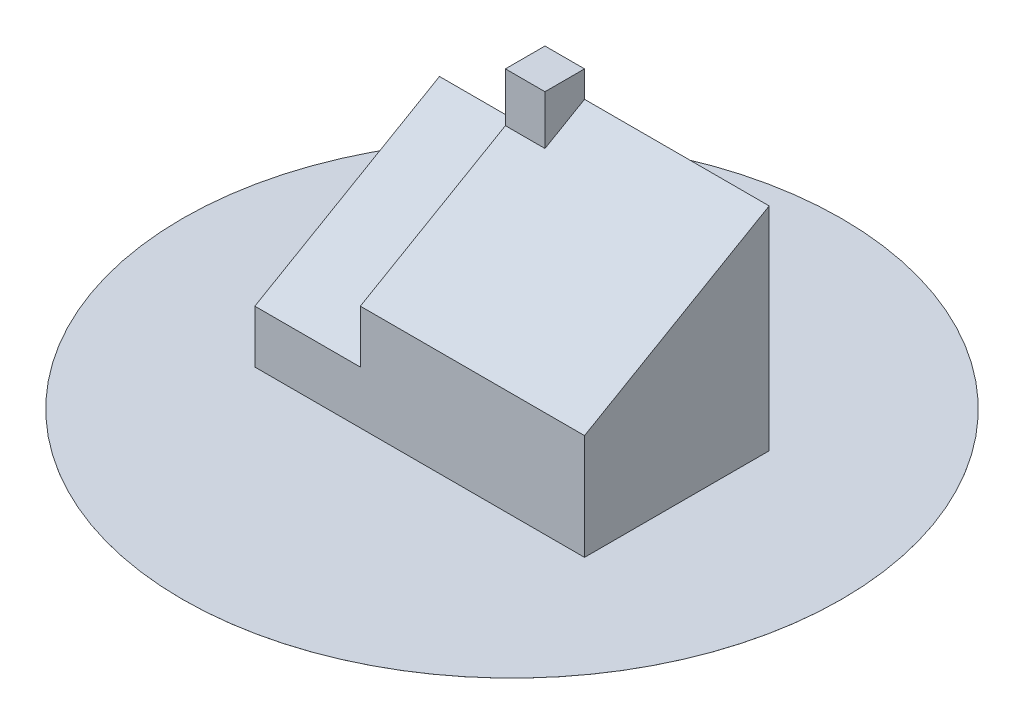
from build123d import *

# Parameters (mm, degrees)
SKETCH1_W           = 125
SKETCH1_H           = 70
EXTRUDE1_DEPTH      = 20
EXTRUDE2_DEPTH      = 40
EXTRUDE3_DEPTH      = 85
SKETCH5_W           = 15
SKETCH5_H           = 15
EXTRUDE5_DEPTH      = 10
EXTRUDE5_DEPTH_BACK = 20
SKETCH6_R           = 125
EXTRUDE6_DEPTH      = 0.01


with BuildPart() as part:
    # Sketch1 → Extrude1 (new body)
    with BuildSketch(Plane(origin=(0, 0, 0), x_dir=(1, 0, 0), z_dir=(0, 1, 0))):
        with Locations((62.5, -35)):
            Rectangle(SKETCH1_W, SKETCH1_H)
    extrude(amount=EXTRUDE1_DEPTH)

    # Sketch2 → Extrude2 (add)
    with BuildSketch(Plane.ZY):
        Polygon((0, 20), (70, 20), (0, 60.414518843), align=None)
    extrude(amount=-EXTRUDE2_DEPTH)

    # Sketch3 → Extrude3 (add)
    with BuildSketch(Plane(origin=(125, 0, 0), x_dir=(0, 0, -1), z_dir=(1, 0, 0))):
        Polygon((-70, 20), (-70, 40), (0, 80.414518843), (0, 20), align=None)
    extrude(amount=-EXTRUDE3_DEPTH)

    # Sketch5 → Extrude5 (add, two sides)
    with BuildSketch(Plane(origin=(0, 80.414518843, 0), x_dir=(-1, 0, 0), z_dir=(0, 1, 0))) as extrude5_sk:
        with Locations((-47.5, 7.5)):
            Rectangle(SKETCH5_W, SKETCH5_H)
    extrude(amount=EXTRUDE5_DEPTH)
    extrude(extrude5_sk.sketch, amount=-EXTRUDE5_DEPTH_BACK)

    # Sketch6 → Extrude6 (add)
    with BuildSketch(Plane(origin=(0, 0, 0), x_dir=(1, 0, 0), z_dir=(0, 1, 0))):
        with Locations(Location((62.5, -35, 0), (0, 0, 270))):  # turned: the seam where the file's is
            Circle(SKETCH6_R)
    extrude(amount=EXTRUDE6_DEPTH)


solid = part.part
